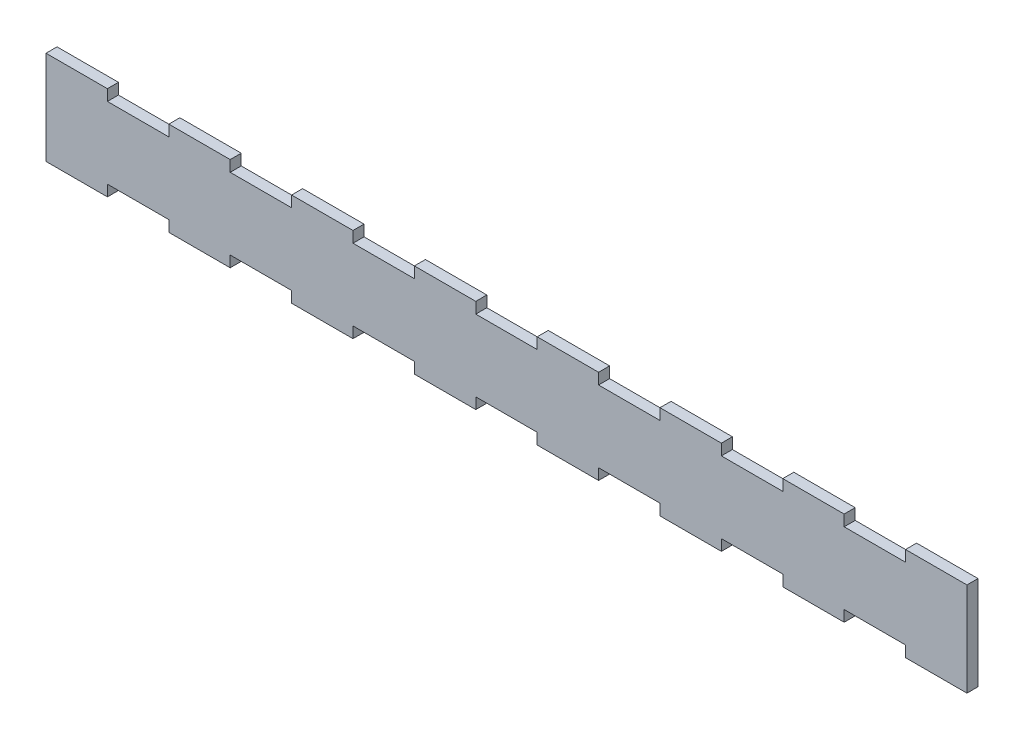
from build123d import *

# Parameters (mm, degrees)
BOSS_EXTRUDE1_DEPTH = 5.4


with BuildPart() as part:
    # Sketch2 → Boss-Extrude1 (new body)
    with BuildSketch(Plane.XY):
        Polygon((220.663898236, 16.745681737), (220.663898236, 22.145681737), (250.663898236, 22.145681737), (250.663898236, 16.745681737), (280.663898236, 16.745681737), (280.663898236, 22.145681737), (310.663898236, 22.145681737), (310.663898236, 16.745681737), (340.663898236, 16.745681737), (340.663898236, 22.145681737), (370.663898236, 22.145681737), (370.663898236, 16.745681737), (400.663898236, 16.745681737), (400.663898236, 22.145681737), (430.663898236, 22.145681737), (430.663898236, 16.745681737), (460.663898236, 16.745681737), (460.663898236, 22.145681737), (490.663898236, 22.145681737), (490.663898236, 16.745681737), (520.663898236, 16.745681737), (520.663898236, 22.145681737), (550.663898236, 22.145681737), (550.663898236, 16.745681737), (580.663898236, 16.745681737), (580.663898236, 22.145681737), (610.663898236, 22.145681737), (610.663898236, 16.745681737), (610.663898236, -18.254318263), (610.663898236, -23.654318263), (580.663898236, -23.654318263), (580.663898236, -18.254318263), (550.663898236, -18.254318263), (550.663898236, -23.654318263), (520.663898236, -23.654318263), (520.663898236, -18.254318263), (490.663898236, -18.254318263), (490.663898236, -23.654318263), (460.663898236, -23.654318263), (460.663898236, -18.254318263), (430.663898236, -18.254318263), (430.663898236, -23.654318263), (400.663898236, -23.654318263), (400.663898236, -18.254318263), (370.663898236, -18.254318263), (370.663898236, -23.654318263), (340.663898236, -23.654318263), (340.663898236, -18.254318263), (310.663898236, -18.254318263), (310.663898236, -23.654318263), (280.663898236, -23.654318263), (280.663898236, -18.254318263), (250.663898236, -18.254318263), (250.663898236, -23.654318263), (220.663898236, -23.654318263), (220.663898236, -18.254318263), (190.663898236, -18.254318263), (190.663898236, -23.654318263), (160.663898236, -23.654318263), (160.663898236, -18.254318263), (160.663898236, 16.745681737), (160.663898236, 22.145681737), (190.663898236, 22.145681737), (190.663898236, 16.745681737), align=None)
    extrude(amount=BOSS_EXTRUDE1_DEPTH)


solid = part.part
